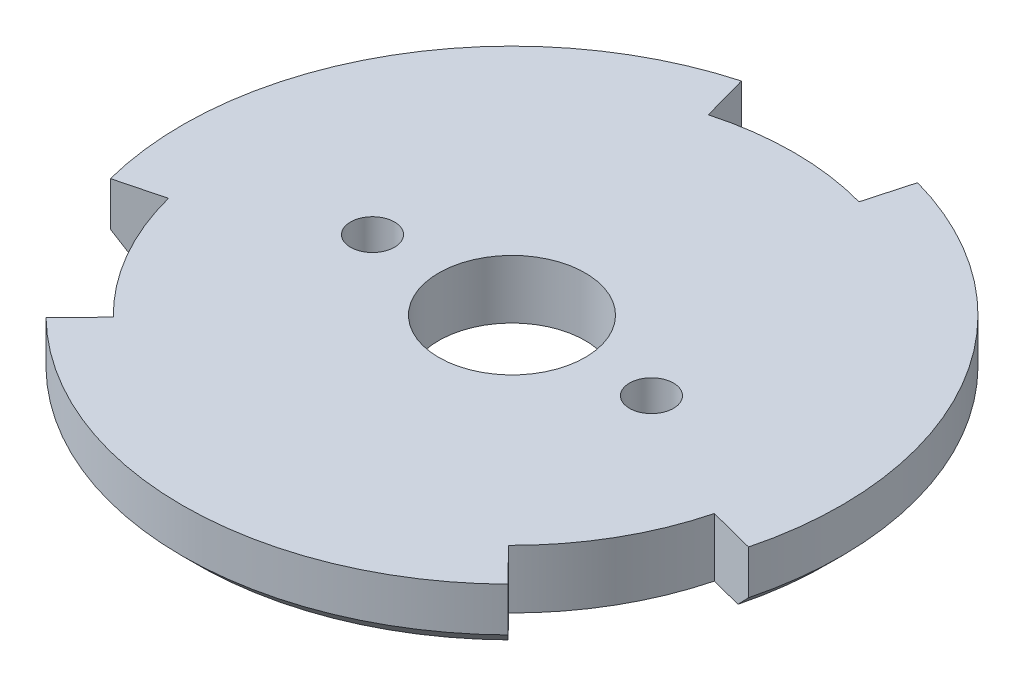
from build123d import *

# Parameters (mm, degrees)
SKETCH1_R           = 22.5
SKETCH1_R_2         = 5
SKETCH1_R_3         = 1.5
BOSS_EXTRUDE1_DEPTH = 4
CHAMFER1_SIZE       = 1
CUT_EXTRUDE1_DEPTH  = 5


with BuildPart() as part:
    # Sketch1 → Boss-Extrude1 (new body)
    with BuildSketch(Plane(origin=(0, 0, 0), x_dir=(1, 0, 0), z_dir=(0, 1, 0))):
        Circle(SKETCH1_R)
        Circle(SKETCH1_R_2, mode=Mode.SUBTRACT)
        with Locations((-9.525, 0)):
            Circle(SKETCH1_R_3, mode=Mode.SUBTRACT)
        with Locations((9.525, 0)):
            Circle(SKETCH1_R_3, mode=Mode.SUBTRACT)
    extrude(amount=BOSS_EXTRUDE1_DEPTH)

    # Chamfer1
    chamfer1_edges = [part.edges().sort_by_distance(p)[0] for p in [
        (-22.5, 0, 0),
    ]]
    chamfer(chamfer1_edges, length=CHAMFER1_SIZE)

    # Sketch2 → Cut-Extrude1 (cut, through all)
    with BuildSketch(Plane(origin=(0, 4, 0), x_dir=(1, 0, 0), z_dir=(0, 1, 0))):
        with BuildLine():
            Line((6.012863462, 21.681685197), (5.14433874, 18.549886224))
            ThreePointArc((5.14433874, 18.549886224), (0, 19.25), (-5.14433874, 18.549886224))
            Line((-5.14433874, 18.549886224), (-6.012863462, 21.681685197))
            ThreePointArc((-6.012863462, 21.681685197), (0, 22.5), (6.012863462, 21.681685197))
        make_face()
        with BuildLine():
            Line((21.783321909, -5.633550091), (18.636842077, -4.819815078))
            ThreePointArc((18.636842077, -4.819815078), (16.670989023, -9.625), (13.492503338, -13.730071146))
            Line((13.492503338, -13.730071146), (15.770458447, -16.048135106))
            ThreePointArc((15.770458447, -16.048135106), (19.485571585, -11.25), (21.783321909, -5.633550091))
        make_face()
        with BuildLine():
            Line((-15.770458447, -16.048135106), (-13.492503338, -13.730071146))
            ThreePointArc((-13.492503338, -13.730071146), (-16.670989023, -9.625), (-18.636842077, -4.819815078))
            Line((-18.636842077, -4.819815078), (-21.783321909, -5.633550091))
            ThreePointArc((-21.783321909, -5.633550091), (-19.485571585, -11.25), (-15.770458447, -16.048135106))
        make_face()
    extrude(amount=-CUT_EXTRUDE1_DEPTH, mode=Mode.SUBTRACT)


solid = part.part
